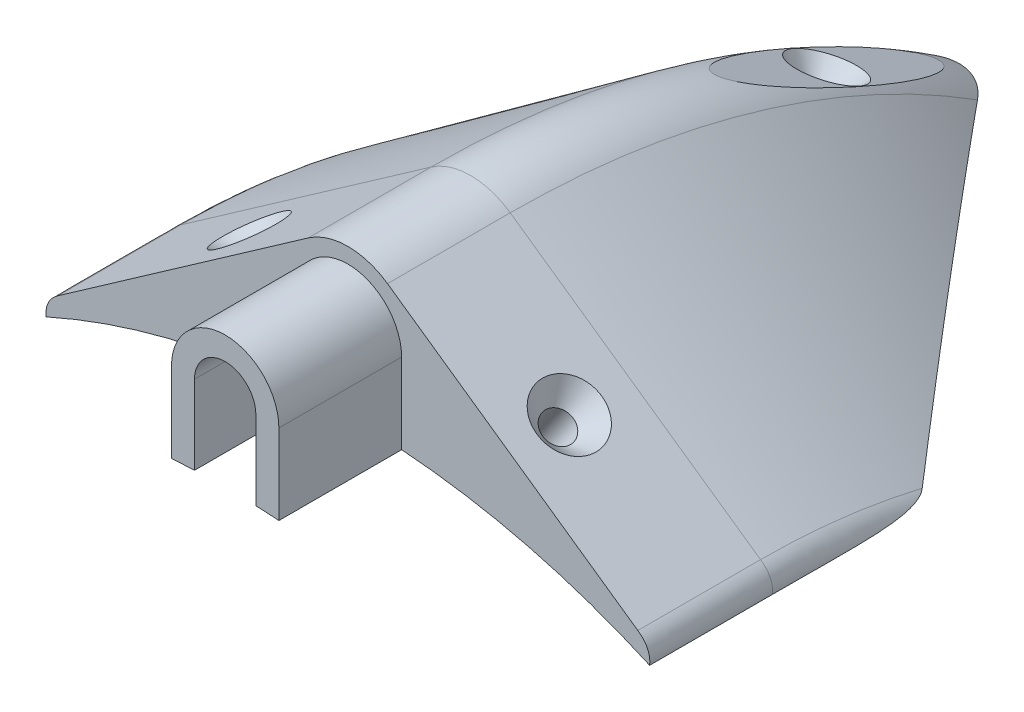
from build123d import *

# Parameters (mm, degrees)
REVOLVE1_ANGLE      = 57
BOSS_EXTRUDE1_DEPTH = 25.4
SKETCH8_R           = 152.4
CUT_EXTRUDE3_DEPTH  = 257.048
SKETCH13_W          = 16.387620484
SKETCH13_H          = 127
CUT_EXTRUDE5_DEPTH  = 1.778
BOSS_EXTRUDE3_DEPTH = 25.4


with BuildPart() as part:
    # Sketch1 → Revolve1 (revolve)
    with BuildSketch(Plane.XY):
        with BuildLine():
            Line((-59.991213716, 144.035687339), (-8.193810242, 180.296949153))
            ThreePointArc((-8.193810242, 180.296949153), (0, 182.88), (8.193810242, 180.296949153))
            Line((8.193810242, 180.296949153), (59.991213716, 144.035687339))
            add(Edge.make_bspline(
                [(59.991213716, 144.035687339), (62.78248672, 142.0840471), (62.441206007, 139.021062406)],
                knots=[0, 0, 0, 1, 1, 1], degree=2))
            ThreePointArc((62.441206007, 139.021062406), (0, 152.4), (-62.441206007, 139.021062406))
            add(Edge.make_bspline(
                [(-59.991213716, 144.035687339), (-62.78248672, 142.0840471), (-62.441206007, 139.021062406)],
                knots=[0, 0, 0, 1, 1, 1], degree=2))
        make_face()
    revolve(axis=Axis((0, 0, 0), (-1, 0, 0)), revolution_arc=REVOLVE1_ANGLE)

    # Sketch3 → Boss-Extrude1 (add)
    with BuildSketch(Plane.XY):
        with BuildLine():
            Line((-59.991213716, 144.035687339), (-8.193810242, 180.296949153))
            ThreePointArc((-8.193810242, 180.296949153), (0, 182.88), (8.193810242, 180.296949153))
            Line((8.193810242, 180.296949153), (59.991213716, 144.035687339))
            add(Edge.make_bspline(
                [(59.991213716, 144.035687339), (62.782486262, 142.084047002), (62.441206007, 139.021062406)],
                knots=[0, 0, 0, 1, 1, 1], degree=2))
            ThreePointArc((62.441206007, 139.021062406), (0, 152.4), (-62.441206007, 139.021062406))
            add(Edge.make_bspline(
                [(-59.991213716, 144.035687339), (-62.782486262, 142.084047002), (-62.441206007, 139.021062406)],
                knots=[0, 0, 0, 1, 1, 1], degree=2))
        make_face()
    extrude(amount=BOSS_EXTRUDE1_DEPTH)

    # Sketch7 → Cut-Revolve2 (revolve, cut)
    with BuildSketch(Plane.XY.offset(12.7)):
        Polygon((-18.85509192, 148.029004366), (-21.456080621, 146.208157646), (-33.109499632, 162.854485329), (-27.584999632, 166.721963764), (-28.163260355, 161.325258604), align=None)
    cut_revolve2 = revolve(axis=Axis((-21.456080621, 146.208157646, 12.7), (-0.57349503, 0.81920904, 0)), mode=Mode.SUBTRACT)

    # Mirror2: Cut-Revolve2 across plane
    add(cut_revolve2.mirror(Plane(origin=(0, 0, 0), x_dir=(0, 0, 1), z_dir=(1, 0, 0))), mode=Mode.SUBTRACT)

    # Sketch8 → Cut-Extrude3 (cut)
    with BuildSketch(Plane.XY.offset(25.4)):
        Circle(SKETCH8_R)
    extrude(amount=-CUT_EXTRUDE3_DEPTH, mode=Mode.SUBTRACT)

    # Sketch13 → Cut-Extrude5 (cut)
    with BuildSketch(Plane(origin=(0, 167.069193294, -74.383997286), x_dir=(1, 0, 0), z_dir=(0, 0.913545458, -0.406736643))):
        Rectangle(SKETCH13_W, SKETCH13_H)
    extrude(amount=-CUT_EXTRUDE5_DEPTH, mode=Mode.SUBTRACT)

    # Sketch14 → Cut-Revolve4 (revolve, cut)
    with BuildSketch(Plane(origin=(0, 0, 0), x_dir=(0, 0, -1), z_dir=(1, 0, 0))):
        Polygon((73.660819534, 165.44490947), (67.500143032, 168.18781937), (69.097003878, 163.000445517), (60.429201972, 143.532243688), (63.3297088, 142.240854846), align=None)
    revolve(axis=Axis((0, 165.44490947, -73.660819534), (0, -0.913545458, 0.406736643)), mode=Mode.SUBTRACT)

    # Sketch15 → Boss-Extrude3 (add)
    with BuildSketch(Plane.XY.offset(25.4)):
        with BuildLine():
            Line((-11.1125, 168.5925), (-11.1125, 151.994316814))
            ThreePointArc((-11.1125, 151.994316814), (-8.732319534, 152.149619111), (-6.35, 152.267650865))
            Line((-6.35, 152.267650865), (-6.35, 168.5925))
            ThreePointArc((-6.35, 168.5925), (0, 174.9425), (6.35, 168.5925))
            Line((6.35, 168.5925), (6.35, 152.267650865))
            ThreePointArc((6.35, 152.267650865), (8.732319534, 152.149619111), (11.1125, 151.994316814))
            Line((11.1125, 151.994316814), (11.1125, 168.5925))
            ThreePointArc((11.1125, 168.5925), (0, 179.705), (-11.1125, 168.5925))
        make_face()
    extrude(amount=BOSS_EXTRUDE3_DEPTH)


solid = part.part
